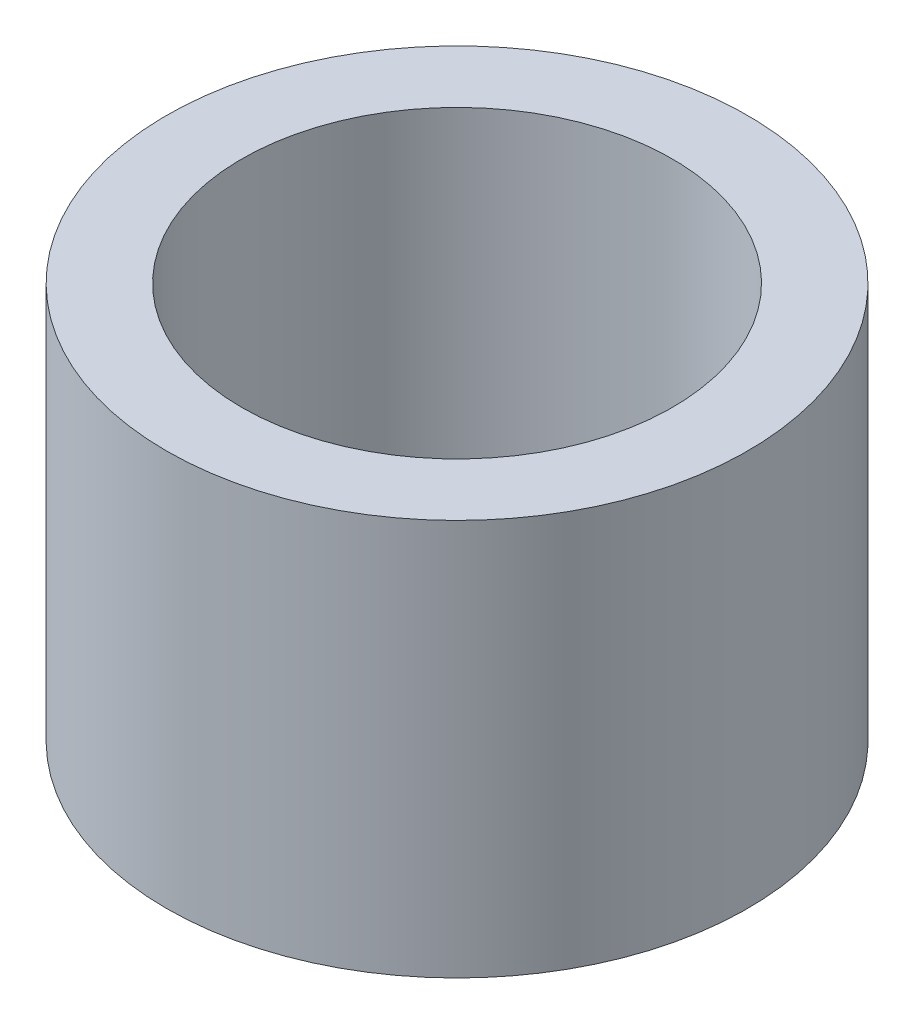
from build123d import *

# Parameters (mm, degrees)
SKETCH1_R           = 11
SKETCH1_R_2         = 8.15
BOSS_EXTRUDE1_DEPTH = 15


with BuildPart() as part:
    # Sketch1 → Boss-Extrude1 (new body)
    with BuildSketch(Plane(origin=(0, 0, 0), x_dir=(1, 0, 0), z_dir=(0, 1, 0))):
        Circle(SKETCH1_R)
        Circle(SKETCH1_R_2, mode=Mode.SUBTRACT)
    extrude(amount=BOSS_EXTRUDE1_DEPTH)


solid = part.part
